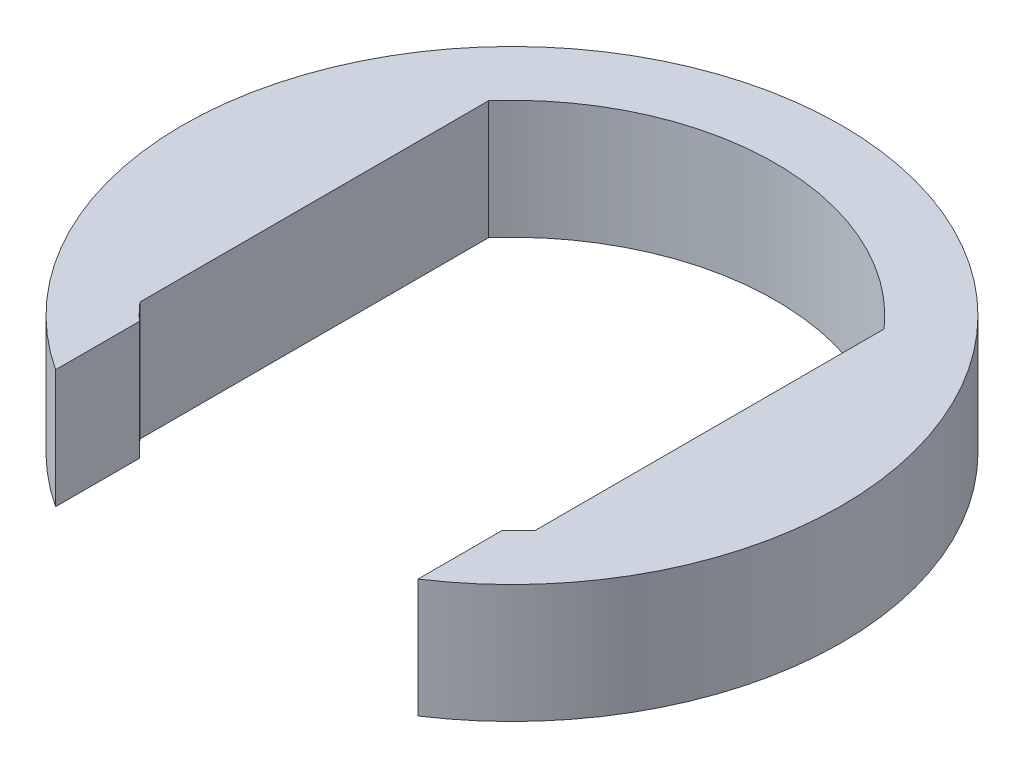
from build123d import *

# Parameters (mm, degrees)
SKETCH1_R           = 5
BOSS_EXTRUDE1_DEPTH = 1.8
CUT_EXTRUDE1_DEPTH  = 2.8


with BuildPart() as part:
    # Sketch1 → Boss-Extrude1 (new body)
    with BuildSketch(Plane(origin=(0, 0, 0), x_dir=(1, 0, 0), z_dir=(0, 1, 0))):
        Circle(SKETCH1_R)
    extrude(amount=BOSS_EXTRUDE1_DEPTH)

    # Sketch2 → Cut-Extrude1 (cut, through all)
    with BuildSketch(Plane(origin=(0, 1.8, 0), x_dir=(1, 0, 0), z_dir=(0, 1, 0))):
        with BuildLine():
            Line((-3, 2.645751311), (-3, -2.645751311))
            ThreePointArc((-3, -2.645751311), (-2.877914777, -2.778058051), (-2.75, -2.90473751))
            Line((-2.75, -2.90473751), (-2.75, -4.175823272))
            ThreePointArc((-2.75, -4.175823272), (0, -5), (2.75, -4.175823272))
            Line((2.75, -4.175823272), (2.75, -2.90473751))
            ThreePointArc((2.75, -2.90473751), (2.877914777, -2.778058051), (3, -2.645751311))
            Line((3, -2.645751311), (3, 2.645751311))
            ThreePointArc((3, 2.645751311), (0, 4), (-3, 2.645751311))
        make_face()
    extrude(amount=-CUT_EXTRUDE1_DEPTH, mode=Mode.SUBTRACT)


solid = part.part
